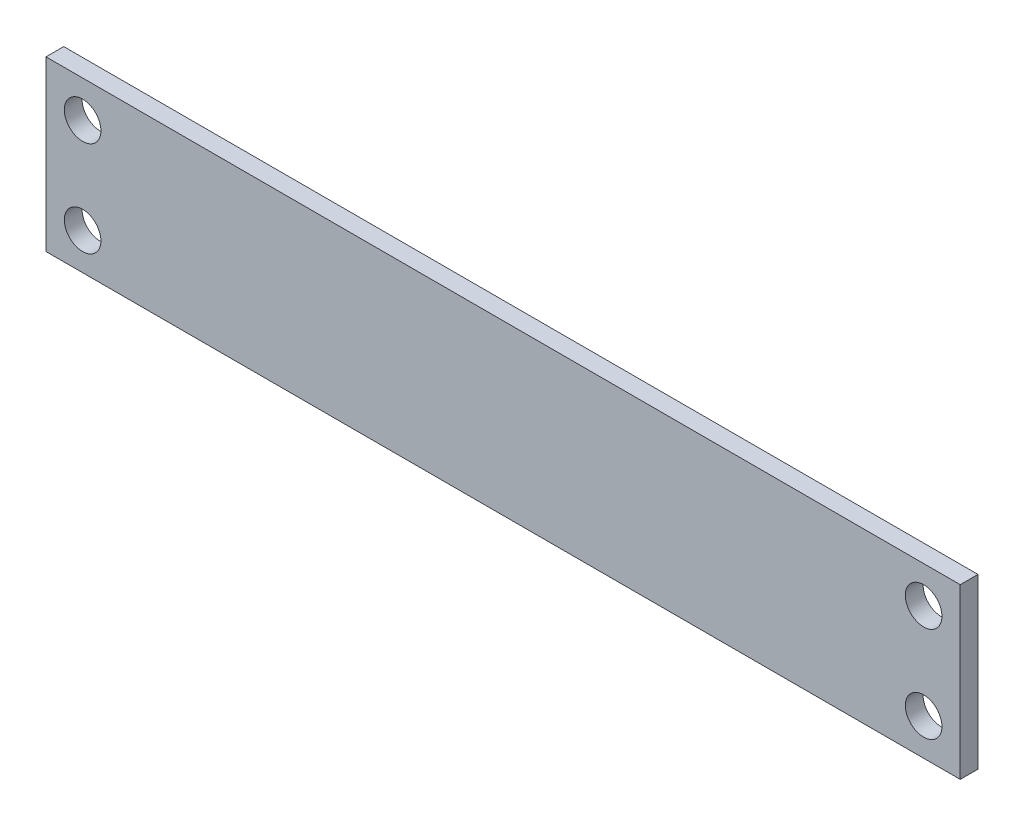
from build123d import *

# Parameters (mm, degrees)
SKETCH_1_W          = 82.4
SKETCH_1_H          = 15.2
EXTRUDE_1_DEPTH     = 1.6
SKETCH_2_R          = 1.65
CUT_EXTRUDE_1_DEPTH = 1.6


with BuildPart() as part:
    # Эскиз1 → Бобышка-Вытянуть1 (new body)
    with BuildSketch(Plane.XY):
        Rectangle(SKETCH_1_W, SKETCH_1_H)
    extrude(amount=EXTRUDE_1_DEPTH)

    # Эскиз2 → Вырез-Вытянуть1 (cut)
    with BuildSketch(Plane.XY.offset(1.6)):
        with Locations((-37.9, 4.3)):
            Circle(SKETCH_2_R)
        with Locations((-37.9, -4.3)):
            Circle(SKETCH_2_R)
        with Locations((37.9, 4.3)):
            Circle(SKETCH_2_R)
        with Locations((37.9, -4.3)):
            Circle(SKETCH_2_R)
    extrude(amount=-CUT_EXTRUDE_1_DEPTH, mode=Mode.SUBTRACT)


solid = part.part
